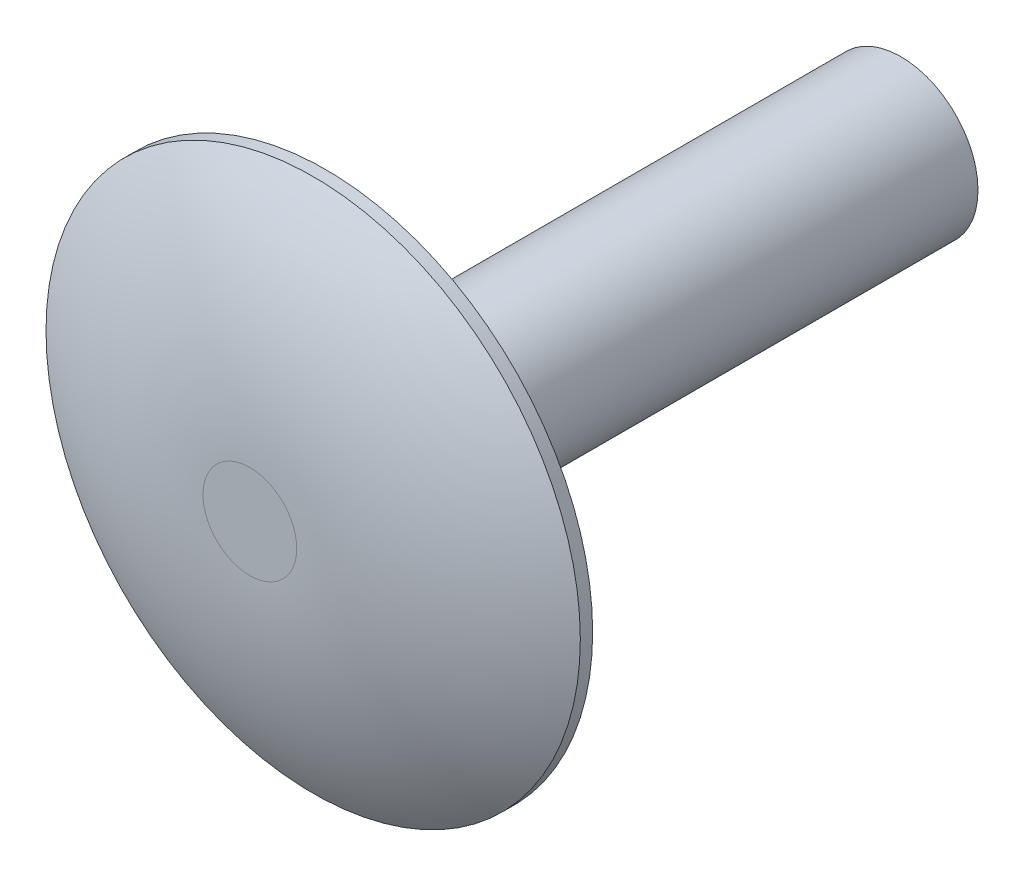
from build123d import *

# Parameters (mm, degrees)
SKETCH1_R           = 8.255
BOSS_EXTRUDE1_DEPTH = 2.3368
SKETCH2_R           = 2.38125
BOSS_EXTRUDE2_DEPTH = 17.78


with BuildPart() as part:
    # Sketch1 → Boss-Extrude1 (new body)
    with BuildSketch(Plane.XY):
        Circle(SKETCH1_R)
    extrude(amount=BOSS_EXTRUDE1_DEPTH)

    # Sketch2 → Boss-Extrude2 (add)
    with BuildSketch(Plane.XY):
        Circle(SKETCH2_R)
    extrude(amount=-BOSS_EXTRUDE2_DEPTH)

    # Sketch3 → Cut-Revolve1 (revolve, cut)
    with BuildSketch(Plane(origin=(0, 0, 0), x_dir=(1, 0, 0), z_dir=(0, 1, 0))):
        with BuildLine():
            ThreePointArc((1.4478, -2.3368), (4.989096566, -1.838155581), (8.255, -0.381))
            Line((8.255, -0.381), (8.255, -2.3368))
            Line((8.255, -2.3368), (1.4478, -2.3368))
        make_face()
    revolve(axis=Axis((0, 0, 2.3368), (0, 0, -1)), mode=Mode.SUBTRACT)


solid = part.part
